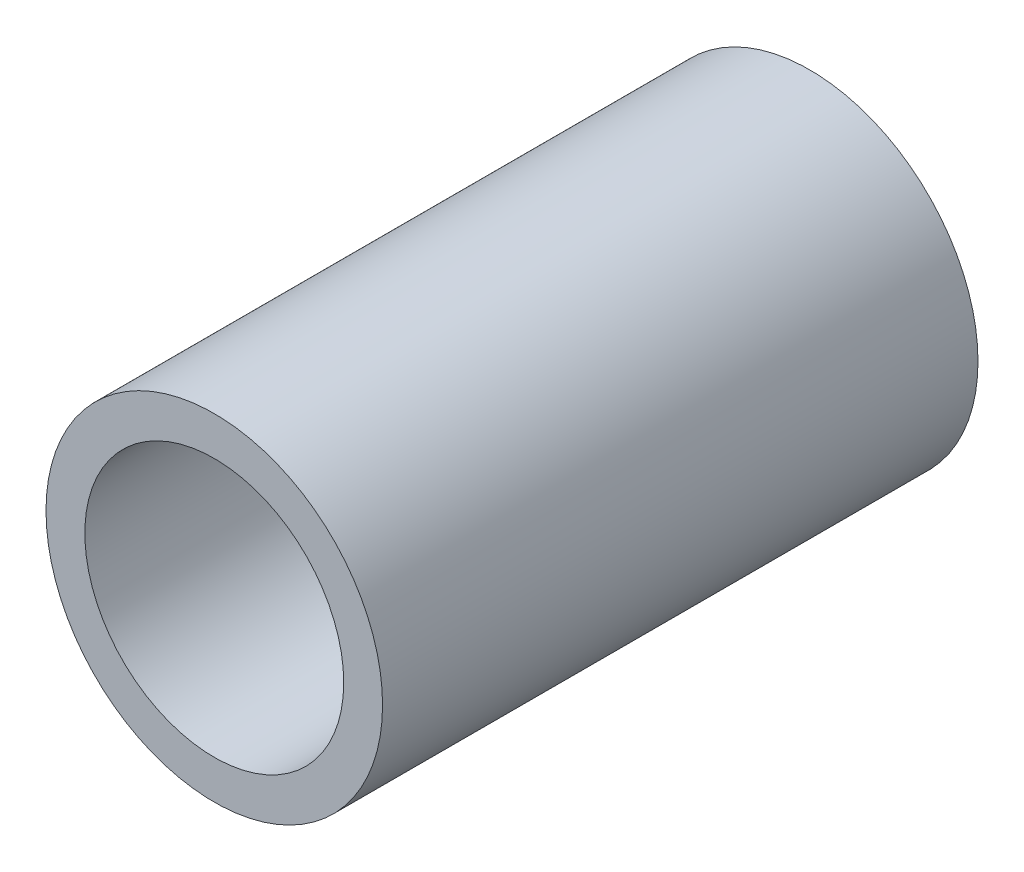
from build123d import *

# Parameters (mm, degrees)
SKETCH1_R           = 19.5
SKETCH1_R_2         = 15
BOSS_EXTRUDE1_DEPTH = 34.5


with BuildPart() as part:
    # Sketch1 → Boss-Extrude1 (new body, symmetric)
    with BuildSketch(Plane.XY):
        Circle(SKETCH1_R)
        Circle(SKETCH1_R_2, mode=Mode.SUBTRACT)
    extrude(amount=BOSS_EXTRUDE1_DEPTH, both=True)


solid = part.part
